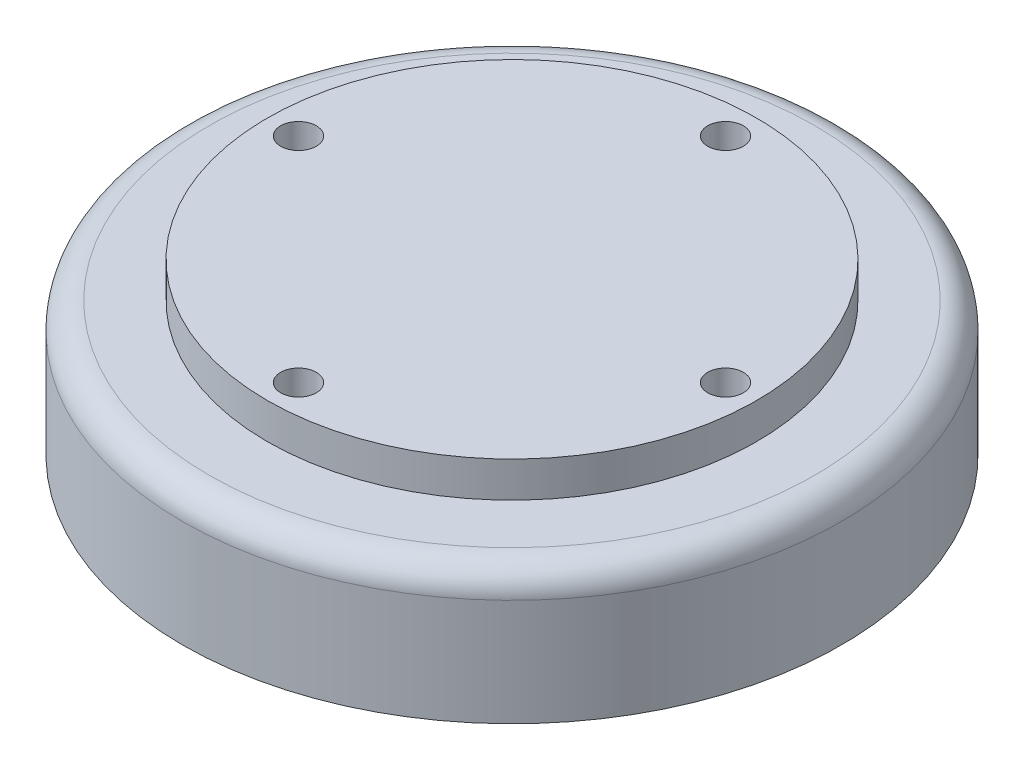
from build123d import *

# Parameters (mm, degrees)
SKETCH2_R           = 27.469
BOSS_EXTRUDE1_DEPTH = 4
SKETCH3_R           = 2
CUT_EXTRUDE1_DEPTH  = 5
SKETCH4_R           = 37
BOSS_EXTRUDE2_DEPTH = 15
CUT_EXTRUDE3_DEPTH  = 8
FILLET1_R           = 3
SKETCH7_R           = 2
CUT_EXTRUDE5_DEPTH  = 25


with BuildPart() as part:
    # Sketch2 → Boss-Extrude1 (new body)
    with BuildSketch(Plane(origin=(0, 0, 0), x_dir=(1, 0, 0), z_dir=(0, 1, 0))):
        Circle(SKETCH2_R)
    extrude(amount=BOSS_EXTRUDE1_DEPTH)

    # Sketch3 → Cut-Extrude1 (cut, through all)
    with BuildSketch(Plane(origin=(0, 4, 0), x_dir=(1, 0, 0), z_dir=(0, 1, 0))):
        with Locations((-23.971, 0)):
            Circle(SKETCH3_R)
        with Locations((0, 23.971)):
            Circle(SKETCH3_R)
        with Locations((23.971, 0)):
            Circle(SKETCH3_R)
        with Locations((0, -23.971)):
            Circle(SKETCH3_R)
    extrude(amount=-CUT_EXTRUDE1_DEPTH, mode=Mode.SUBTRACT)

    # Sketch4 → Boss-Extrude2 (add)
    with BuildSketch(Plane.XZ):
        Circle(SKETCH4_R)
    extrude(amount=BOSS_EXTRUDE2_DEPTH)

    # Sketch6 → Cut-Extrude3 (cut)
    with BuildSketch(Plane.XZ.offset(15)):
        Polygon((-29.369836479, 13.518359314), (-26.392160823, -18.675844839), (2.977675656, -32.194204153), (29.369836479, -13.518359314), (26.392160823, 18.675844839), (-2.977675656, 32.194204153), align=None)
    extrude(amount=-CUT_EXTRUDE3_DEPTH, mode=Mode.SUBTRACT)

    # Fillet1
    fillet1_edges = [part.edges().sort_by_distance(p)[0] for p in [
        (-37, 0, 0),
    ]]
    fillet(fillet1_edges, radius=FILLET1_R)

    # Sketch7 → Cut-Extrude5 (cut, through all)
    with BuildSketch(Plane(origin=(0, 9, 0), x_dir=(1, 0, 0), z_dir=(0, 1, 0))):
        with Locations((0, 23.971)):
            Circle(SKETCH7_R)
        with Locations((23.971, 0)):
            Circle(SKETCH7_R)
        with Locations((0, -23.971)):
            Circle(SKETCH7_R)
        with Locations((-23.971, 0)):
            Circle(SKETCH7_R)
    extrude(amount=-CUT_EXTRUDE5_DEPTH, mode=Mode.SUBTRACT)


solid = part.part
